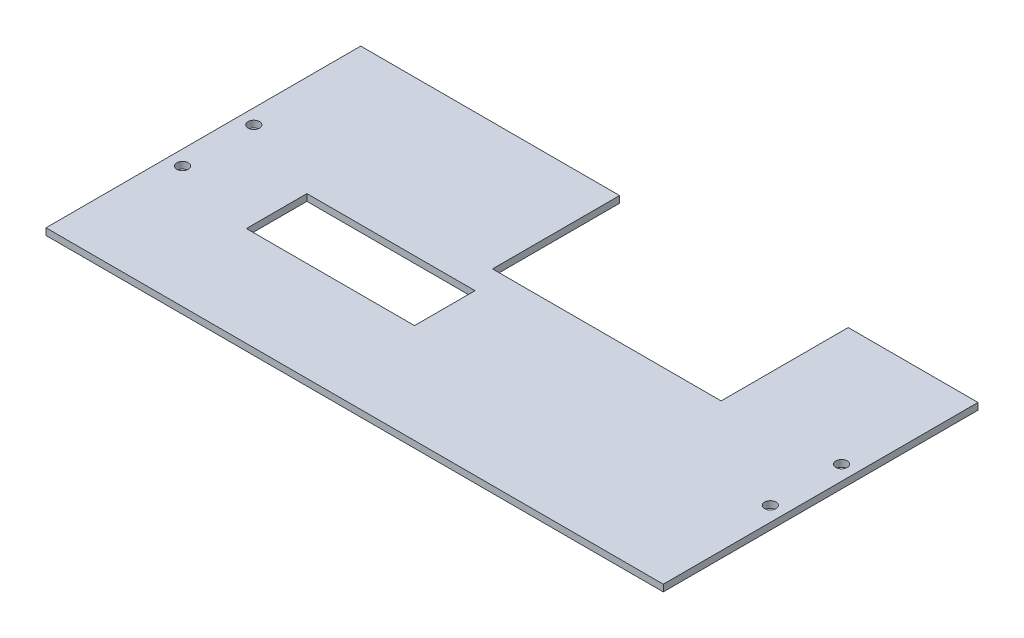
from build123d import *

# Parameters (mm, degrees)
SKETCH1_W             = 233.172
SKETCH1_H             = 118.880382
BOSS_EXTRUDE1_DEPTH   = 2.54
F_6_CLEARANCE_HOLE1_D = 4.3053
SKETCH4_W             = 86.36
SKETCH4_H             = 48.006
CUT_EXTRUDE1_DEPTH    = 3.54
SKETCH5_W             = 63.5
SKETCH5_H             = 22.86
CUT_EXTRUDE2_DEPTH    = 3.54


with BuildPart() as part:
    # Sketch1 → Boss-Extrude1 (new body)
    with BuildSketch(Plane(origin=(0, 0, 0), x_dir=(1, 0, 0), z_dir=(0, 1, 0))):
        Rectangle(SKETCH1_W, SKETCH1_H)
    extrude(amount=BOSS_EXTRUDE1_DEPTH)

    # #6 Clearance Hole1 (through all)
    with Locations(Plane(origin=(0, 2.54, 0), x_dir=(1, 0, 0), z_dir=(0, 1, 0))):
        with Locations((111.0107, 13.474573), (111.0107, -13.4511034), (-111.0107, 13.474573), (-111.0107, -13.4511034)):
            Hole(F_6_CLEARANCE_HOLE1_D / 2)

    # Sketch4 → Cut-Extrude1 (cut, through all)
    with BuildSketch(Plane(origin=(0, 2.54, 0), x_dir=(1, 0, 0), z_dir=(0, 1, 0))):
        with Locations((24.379682, 35.437191)):
            Rectangle(SKETCH4_W, SKETCH4_H)
    extrude(amount=-CUT_EXTRUDE1_DEPTH, mode=Mode.SUBTRACT)

    # Sketch5 → Cut-Extrude2 (cut, through all)
    with BuildSketch(Plane(origin=(0, 2.54, 0), x_dir=(1, 0, 0), z_dir=(0, 1, 0))):
        with Locations((-46.736, -10.409809)):
            Rectangle(SKETCH5_W, SKETCH5_H)
    extrude(amount=-CUT_EXTRUDE2_DEPTH, mode=Mode.SUBTRACT)


solid = part.part
